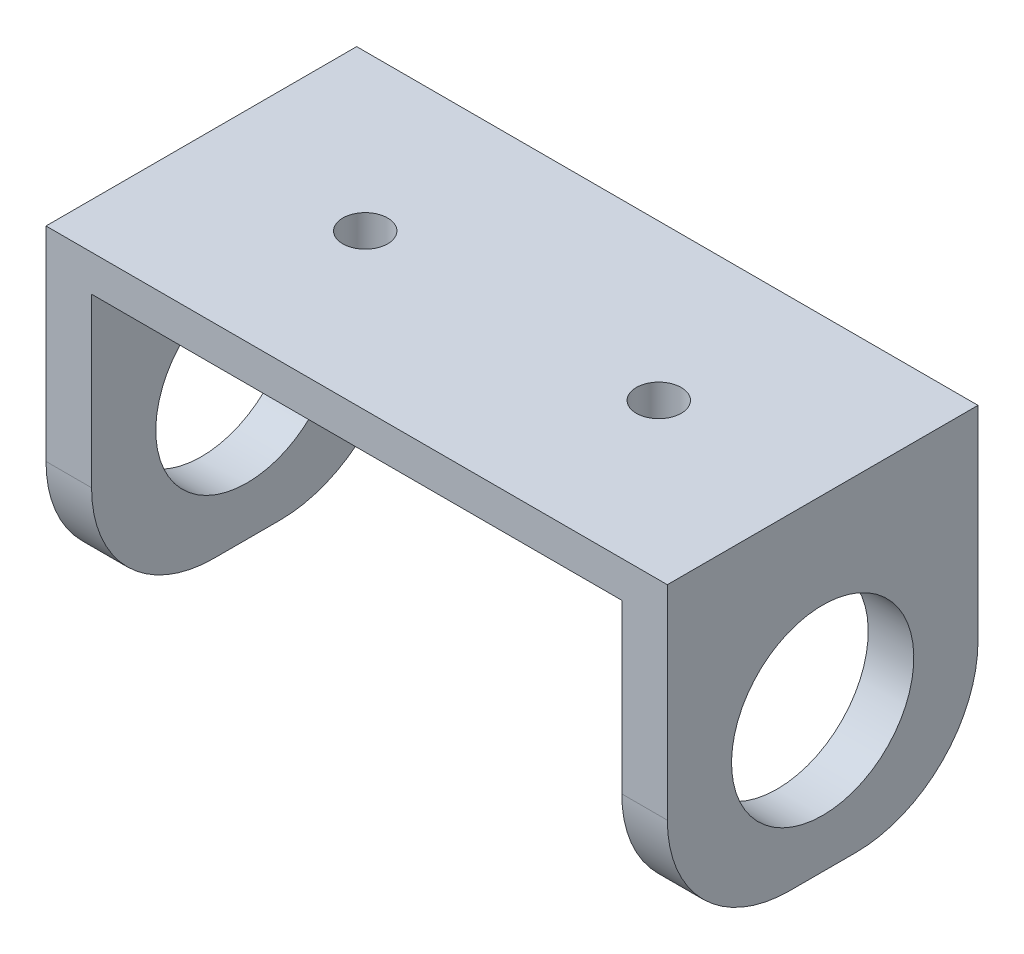
from build123d import *

# Parameters (mm, degrees)
BOSS_EXTRUDE1_DEPTH = 38.1
SKETCH5_R           = 11.176
CUT_EXTRUDE1_DEPTH  = 38.1
FILLET1_R           = 15
SKETCH6_R           = 1.51
CUT_EXTRUDE2_DEPTH  = 10
SKETCH11_R          = 2.75
CUT_EXTRUDE5_DEPTH  = 5
SKETCH12_R          = 2.75
BOSS_EXTRUDE2_DEPTH = 3
SKETCH13_R          = 1.5
CUT_EXTRUDE6_DEPTH  = 3


with BuildPart() as part:
    # Sketch1 → Boss-Extrude1 (new body)
    with BuildSketch(Plane.XY):
        Polygon((-76.717654375, 44.038289207), (-0.517654375, 44.038289207), (-0.517654375, 4.028289207), (-6.105654375, 4.028289207), (-6.105654375, 39.588289207), (-71.129654375, 39.588289207), (-71.129654375, 4.028289207), (-76.717654375, 4.028289207), align=None)
    extrude(amount=BOSS_EXTRUDE1_DEPTH)

    # Sketch5 → Cut-Extrude1 (cut)
    with BuildSketch(Plane.ZY.offset(6.105654375)):
        with Locations((19.05, 21.178289207)):
            Circle(SKETCH5_R)
    cut_extrude1 = extrude(amount=-CUT_EXTRUDE1_DEPTH, mode=Mode.SUBTRACT)

    # Mirror3: Cut-Extrude1 across plane
    add(cut_extrude1.mirror(Plane.ZY.offset(38.617654375)), mode=Mode.SUBTRACT)

    # Fillet1
    fillet1_edges = [part.edges().sort_by_distance(p)[0] for p in [
        (-73.923654375, 4.028289207, 0),
        (-3.311654375, 4.028289207, 38.1),
        (-73.923654375, 4.028289207, 38.1),
        (-3.311654375, 4.028289207, 0),
    ]]
    fillet(fillet1_edges, radius=FILLET1_R)

    # Sketch6 → Cut-Extrude2 (cut)
    with BuildSketch(Plane(origin=(0, 44.038289207, 0), x_dir=(1, 0, 0), z_dir=(0, 1, 0))):
        with Locations((-56.617654375, -19.05)):
            Circle(SKETCH6_R)
        with Locations((-20.617654375, -19.05)):
            Circle(SKETCH6_R)
    extrude(amount=-CUT_EXTRUDE2_DEPTH, mode=Mode.SUBTRACT)

    # Sketch11 → Cut-Extrude5 (cut)
    with BuildSketch(Plane(origin=(0, 44.038289207, 0), x_dir=(1, 0, 0), z_dir=(0, 1, 0))):
        with Locations((-56.617654375, -19.05)):
            Circle(SKETCH11_R)
        with Locations((-20.617654375, -19.05)):
            Circle(SKETCH11_R)
    extrude(amount=-CUT_EXTRUDE5_DEPTH, mode=Mode.SUBTRACT)

    # Sketch12 → Boss-Extrude2 (add)
    with BuildSketch(Plane(origin=(0, 0, 0), x_dir=(-1, 0, 0), z_dir=(0, 0, -1))):
        with BuildLine():
            Line((6.105654375, 39.588289207), (71.129654375, 39.588289207))
            Line((71.129654375, 39.588289207), (71.129654375, 28.628518045))
            Line((71.129654375, 28.628518045), (65.259425536, 28.628518045))
            ThreePointArc((65.259425536, 28.628518045), (62.352582017, 29.420734639), (60.249654375, 31.578289207))
            ThreePointArc((60.249654375, 31.578289207), (59.564079492, 33.126822105), (57.949654375, 33.638289207))
            Line((57.949654375, 33.638289207), (19.045654375, 33.638289207))
            ThreePointArc((19.045654375, 33.638289207), (17.589014406, 33.034929176), (16.985654375, 31.578289207))
            ThreePointArc((16.985654375, 31.578289207), (14.882724316, 29.420741304), (11.975883214, 28.628527574))
            Line((11.975883214, 28.628527574), (6.105654375, 28.628527574))
            Line((6.105654375, 28.628527574), (6.105654375, 39.588289207))
        make_face()
        with Locations((65.009654375, 33.638289207)):
            Circle(SKETCH12_R, mode=Mode.SUBTRACT)
        with Locations((11.985654375, 33.638289207)):
            Circle(SKETCH12_R, mode=Mode.SUBTRACT)
    extrude(amount=-BOSS_EXTRUDE2_DEPTH)

    # Sketch13 → Cut-Extrude6 (cut)
    with BuildSketch(Plane.XY.offset(3)):
        with Locations((-28.497654375, 36.613289207)):
            Circle(SKETCH13_R)
        with Locations((-48.497654375, 36.613289207)):
            Circle(SKETCH13_R)
    extrude(amount=-CUT_EXTRUDE6_DEPTH, mode=Mode.SUBTRACT)


solid = part.part
